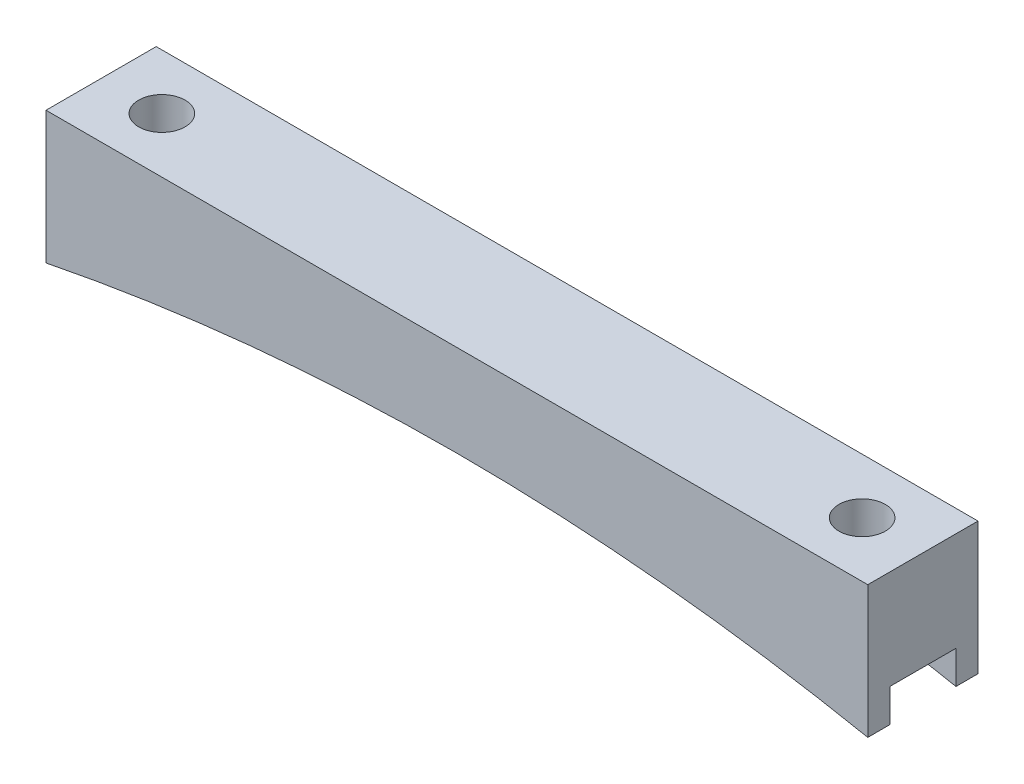
from build123d import *

# Parameters (mm, degrees)
BOSS_EXTRUDE1_DEPTH = 12.7
SKETCH2_R           = 2.675
CUT_EXTRUDE1_DEPTH  = 16.24
SKETCH3_W           = 7.62
SKETCH3_H           = 3.81
CUT_EXTRUDE2_DEPTH  = 95.6800001


with BuildPart() as part:
    # Sketch1 → Boss-Extrude1 (new body)
    with BuildSketch(Plane.XY):
        with BuildLine():
            Line((-47.34, 0), (47.34, 0))
            Line((47.34, 0), (47.34, -15.24))
            ThreePointArc((47.34, -15.24), (0, -10.550681078), (-47.34, -15.24))
            Line((-47.34, -15.24), (-47.34, 0))
        make_face()
    extrude(amount=BOSS_EXTRUDE1_DEPTH)

    # Sketch2 → Cut-Extrude1 (cut, through all)
    with BuildSketch(Plane(origin=(0, 0, 0), x_dir=(1, 0, 0), z_dir=(0, 1, 0))):
        with Locations((-40.34, -6.35)):
            Circle(SKETCH2_R)
        with Locations((40.34, -6.35)):
            Circle(SKETCH2_R)
    extrude(amount=-CUT_EXTRUDE1_DEPTH, mode=Mode.SUBTRACT)

    # Sketch3 → Cut-Extrude2 (cut, through all)
    with BuildSketch(Plane(origin=(47.34, 0, 0), x_dir=(0, 0, -1), z_dir=(1, 0, 0))):
        with Locations((-6.35, -13.335)):
            Rectangle(SKETCH3_W, SKETCH3_H)
    extrude(amount=-CUT_EXTRUDE2_DEPTH, mode=Mode.SUBTRACT)


solid = part.part
